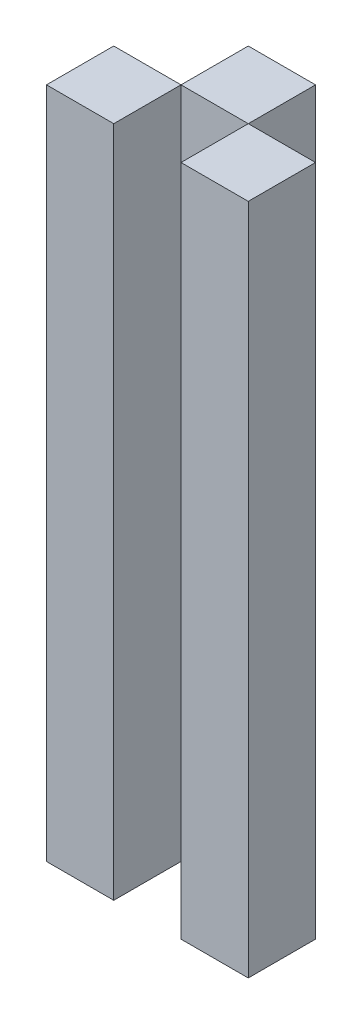
from build123d import *

# Parameters (mm, degrees)
SKETCH1_W          = 25.395282645
SKETCH1_H          = 254
EXTRUSION2_DEPTH   = 25.4
SKETCH1_W_2        = 25.404717355
EXTRUSION2_2_DEPTH = 25.4
SKETCH2_W          = 25.4
SKETCH2_H          = 254
EXTRUSION3_DEPTH   = 25.4


with BuildPart() as part:
    # Sketch1 → Extrusion2 (new body)
    with BuildSketch(Plane.XY):
        with Locations((63.502358677, 127)):
            Rectangle(SKETCH1_W, SKETCH1_H)
    extrude(amount=EXTRUSION2_DEPTH)


with BuildPart() as body_2:
    # Sketch1 → Extrusion2 2 (new body)
    with BuildSketch(Plane.XY):
        with Locations((12.702358678, 127)):
            Rectangle(SKETCH1_W_2, SKETCH1_H)
    extrude(amount=EXTRUSION2_2_DEPTH)


with BuildPart() as body_3:
    # Sketch2 → Extrusion3 (new body)
    with BuildSketch(Plane(origin=(0, 0, 0), x_dir=(-1, 0, 0), z_dir=(0, 0, -1))):
        with Locations((-38.104717355, 127)):
            Rectangle(SKETCH2_W, SKETCH2_H)
    extrude(amount=EXTRUSION3_DEPTH)


solid = Compound([part.part, body_2.part, body_3.part])
